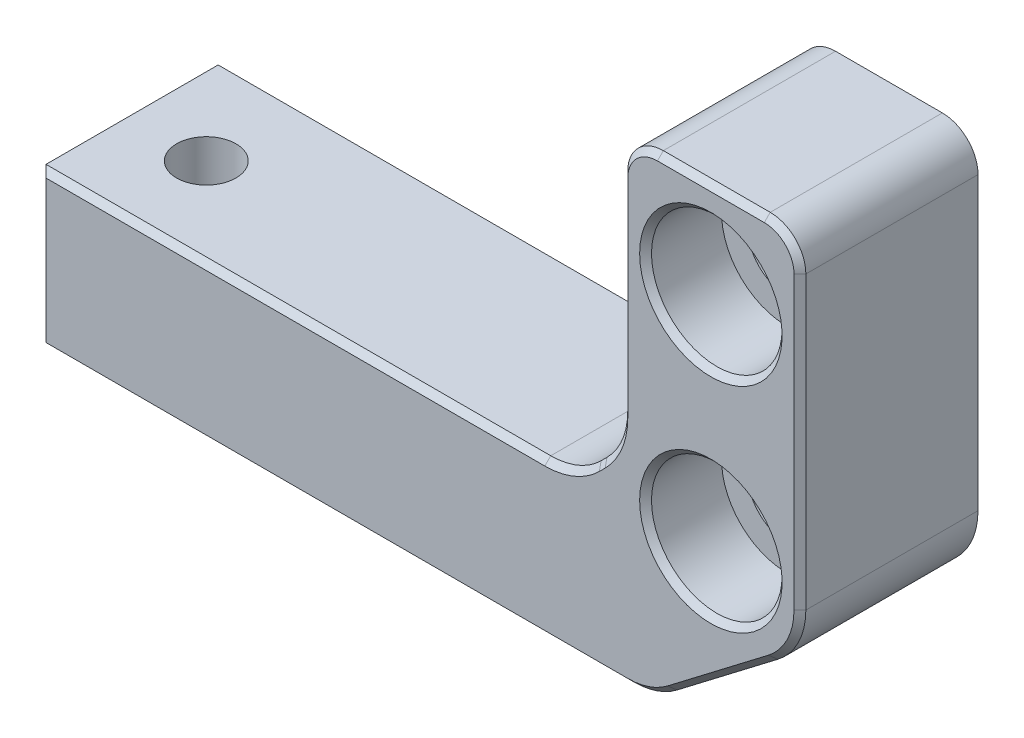
from build123d import *

# Parameters (mm, degrees)
BOSS_EXTRUDE1_DEPTH                                 = 15
CBORE_FOR_M6_HEX_SOCKET_HEAD_CAP_SCREW1_D           = 6.6
CBORE_FOR_M6_HEX_SOCKET_HEAD_CAP_SCREW1_CBORE_D     = 11
CBORE_FOR_M6_HEX_SOCKET_HEAD_CAP_SCREW1_CBORE_DEPTH = 6.4
TAP_DRILL_FOR_M6_TAP1_D                             = 5
CHAMFER1_SIZE                                       = 0.5


with BuildPart() as part:
    # Sketch1 → Boss-Extrude1 (new body)
    with BuildSketch(Plane.XY):
        with BuildLine():
            Line((22.658191436, -18.599539786), (31.14347281, -12.114258412))
            ThreePointArc((31.14347281, -12.114258412), (32.878700441, -10.006041207), (33.5, -7.347172731))
            Line((33.5, -7.347172731), (33.5, 17.167545894))
            ThreePointArc((33.5, 17.167545894), (32.621320344, 19.288866238), (30.5, 20.167545894))
            Line((30.5, 20.167545894), (21.5, 20.167545894))
            ThreePointArc((21.5, 20.167545894), (19.378679656, 19.288866238), (18.5, 17.167545894))
            Line((18.5, 17.167545894), (18.5, -0.347172731))
            ThreePointArc((18.5, -0.347172731), (18.043277195, -2.643273326), (16.742640687, -4.589813418))
            Line((16.742640687, -4.589813418), (16.257359313, -5.075094793))
            ThreePointArc((16.257359313, -5.075094793), (14.31081922, -6.375731301), (12.014718626, -6.832454106))
            Line((12.014718626, -6.832454106), (-30.5, -6.832454106))
            Line((-30.5, -6.832454106), (-30.5, -19.832454106))
            Line((-30.5, -19.832454106), (19.014718626, -19.832454106))
            ThreePointArc((19.014718626, -19.832454106), (20.937930252, -19.51587359), (22.658191436, -18.599539786))
        make_face()
    extrude(amount=BOSS_EXTRUDE1_DEPTH)

    # CBORE for M6 Hex Socket Head Cap Screw1 (through all)
    with Locations(Plane.XY.offset(15)):
        with Locations((26, 12.167545894), (26, -5.832454106)):
            CounterBoreHole(CBORE_FOR_M6_HEX_SOCKET_HEAD_CAP_SCREW1_D / 2, CBORE_FOR_M6_HEX_SOCKET_HEAD_CAP_SCREW1_CBORE_D / 2, CBORE_FOR_M6_HEX_SOCKET_HEAD_CAP_SCREW1_CBORE_DEPTH)

    # Tap Drill for M6 Tap1 (through all)
    with Locations(Plane(origin=(0, -6.832454106, 0), x_dir=(1, 0, 0), z_dir=(0, 1, 0))):
        with Locations((-24, -7.5)):
            Hole(TAP_DRILL_FOR_M6_TAP1_D / 2)

    # Chamfer1
    chamfer1_edges = [part.edges().sort_by_distance(p)[0] for p in [
        (20.937930252, -19.51587359, 15),
        (26.900832123, -15.356899099, 15),
        (32.878700441, -10.006041207, 15),
        (33.5, 4.910186582, 15),
        (32.621320344, 19.288866238, 15),
        (26, 20.167545894, 15),
        (19.378679656, 19.288866238, 15),
        (18.5, 8.410186582, 15),
        (18.043277195, -2.643273326, 15),
        (16.5, -4.832454106, 15),
        (-30.5, -13.332454106, 15),
        (14.31081922, -6.375731301, 15),
        (20.5, -5.832454106, 15),
        (-9.242640687, -6.832454106, 15),
        (20.5, 12.167545894, 15),
        (-5.742640687, -19.832454106, 15),
    ]]
    chamfer(chamfer1_edges, length=CHAMFER1_SIZE)


solid = part.part
